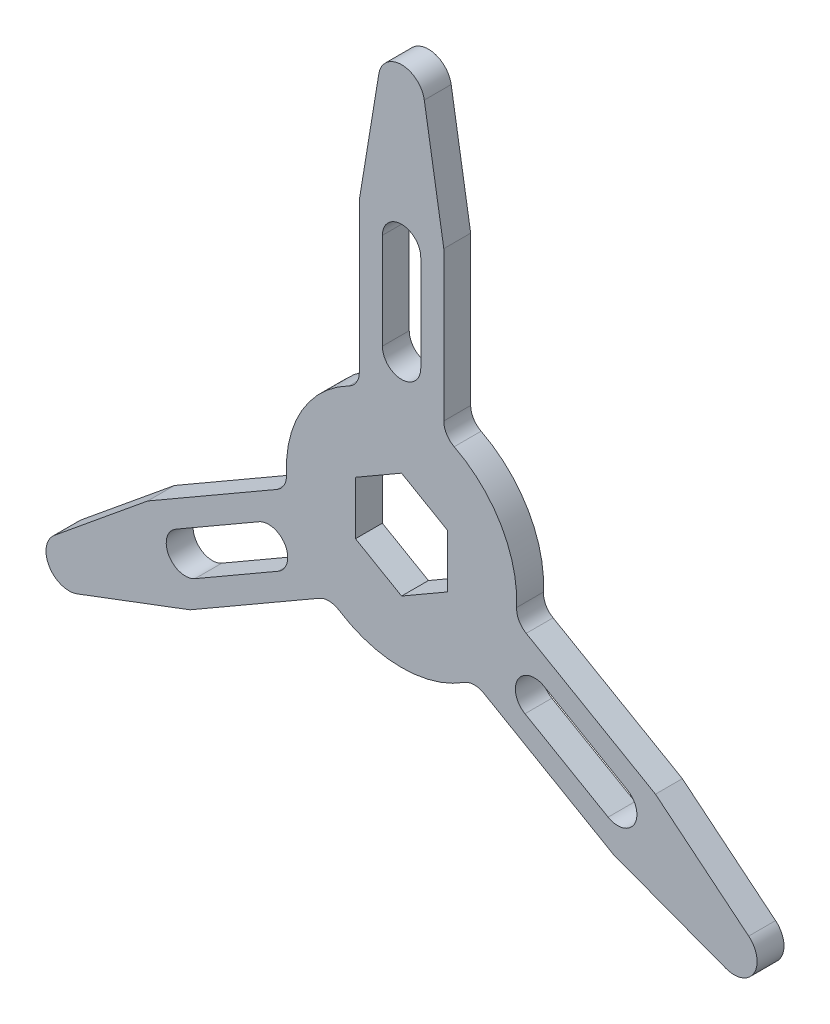
from build123d import *

# Parameters (mm, degrees)
P_IDAT_VYSUNUT_M1_DEPTH = 7


with BuildPart() as part:
    # Skica1 → Přidat vysunutím1 (new body)
    with BuildSketch(Plane.XY):
        with BuildLine():
            Line((-11, 31.128764833), (-11, 70))
            Line((-11, 70), (-5.920908656, 100.97099984))
            ThreePointArc((-5.920908656, 100.97099984), (0, 106), (5.920908656, 100.97099984))
            Line((5.920908656, 100.97099984), (11, 70))
            Line((11, 70), (11, 31.128764833))
            ThreePointArc((11, 31.128764833), (11.732180215, 28.523824471), (13.714285714, 26.681798428))
            ThreePointArc((13.714285714, 26.681798428), (25.980762114, 15), (29.964258114, -1.463979391))
            ThreePointArc((29.964258114, -1.463979391), (30.568446713, -4.101546127), (32.458301133, -6.038102975))
            Line((32.458301133, -6.038102975), (66.121778265, -25.473720558))
            Line((66.121778265, -25.473720558), (90.403905235, -45.357842611))
            ThreePointArc((90.403905235, -45.357842611), (91.798692801, -53), (84.482996579, -55.61315723))
            Line((84.482996579, -55.61315723), (55.121778265, -44.526279442))
            Line((55.121778265, -44.526279442), (21.458301133, -25.090661858))
            ThreePointArc((21.458301133, -25.090661858), (18.836266498, -24.422278344), (16.2499724, -25.217819037))
            ThreePointArc((16.2499724, -25.217819037), (0, -30), (-16.2499724, -25.217819037))
            ThreePointArc((-16.2499724, -25.217819037), (-18.836266498, -24.422278344), (-21.458301133, -25.090661858))
            Line((-21.458301133, -25.090661858), (-55.121778265, -44.526279442))
            Line((-55.121778265, -44.526279442), (-84.482996579, -55.61315723))
            ThreePointArc((-84.482996579, -55.61315723), (-91.798692801, -53), (-90.403905235, -45.357842611))
            Line((-90.403905235, -45.357842611), (-66.121778265, -25.473720558))
            Line((-66.121778265, -25.473720558), (-32.458301133, -6.038102975))
            ThreePointArc((-32.458301133, -6.038102975), (-30.568446713, -4.101546127), (-29.964258114, -1.463979391))
            ThreePointArc((-29.964258114, -1.463979391), (-25.980762114, 15), (-13.714285714, 26.681798428))
            ThreePointArc((-13.714285714, 26.681798428), (-11.732180215, 28.523824471), (-11, 31.128764833))
        make_face()
        with BuildLine():
            Line((-5, 65), (-5, 40))
            ThreePointArc((-5, 40), (0, 35), (5, 40))
            Line((5, 40), (5, 65))
            ThreePointArc((5, 65), (0, 70), (-5, 65))
        make_face(mode=Mode.SUBTRACT)
        with BuildLine():
            Line((58.791651246, -28.169872981), (37.141016151, -15.669872981))
            ThreePointArc((37.141016151, -15.669872981), (30.310889132, -17.5), (32.141016151, -24.330127019))
            Line((32.141016151, -24.330127019), (53.791651246, -36.830127019))
            ThreePointArc((53.791651246, -36.830127019), (60.621778265, -35), (58.791651246, -28.169872981))
        make_face(mode=Mode.SUBTRACT)
        Polygon((0, -13.856406461), (12, -6.92820323), (12, 6.92820323), (0, 13.856406461), (-12, 6.92820323), (-12, -6.92820323), align=None, mode=Mode.SUBTRACT)
        with BuildLine():
            Line((-53.791651246, -36.830127019), (-32.141016151, -24.330127019))
            ThreePointArc((-32.141016151, -24.330127019), (-30.310889132, -17.5), (-37.141016151, -15.669872981))
            Line((-37.141016151, -15.669872981), (-58.791651246, -28.169872981))
            ThreePointArc((-58.791651246, -28.169872981), (-60.621778265, -35), (-53.791651246, -36.830127019))
        make_face(mode=Mode.SUBTRACT)
    extrude(amount=P_IDAT_VYSUNUT_M1_DEPTH)


solid = part.part
